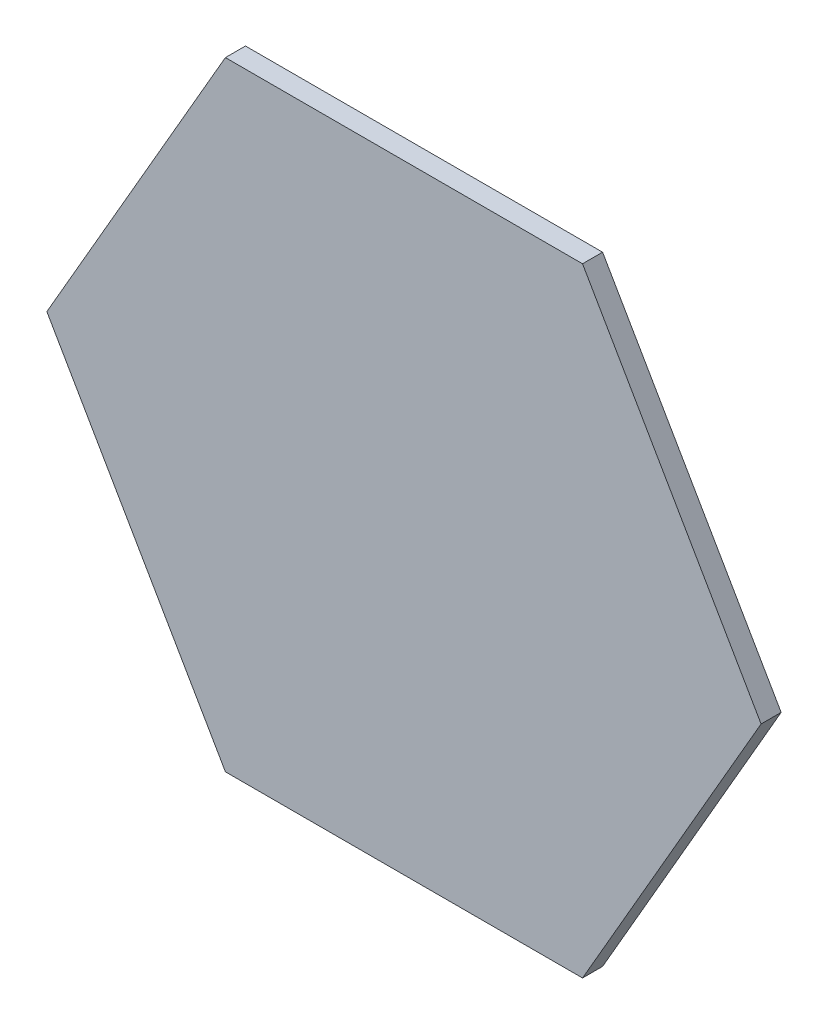
from build123d import *

# Parameters (mm, degrees)
BOSS_EXTRUDE1_DEPTH = 2.54


with BuildPart() as part:
    # Sketch1 → Boss-Extrude1 (new body)
    with BuildSketch(Plane.XY):
        Polygon((45.212, 0), (22.606, 39.154740556), (-22.606, 39.154740556), (-45.212, 0), (-22.606, -39.154740556), (22.606, -39.154740556), align=None)
    extrude(amount=BOSS_EXTRUDE1_DEPTH)


solid = part.part
